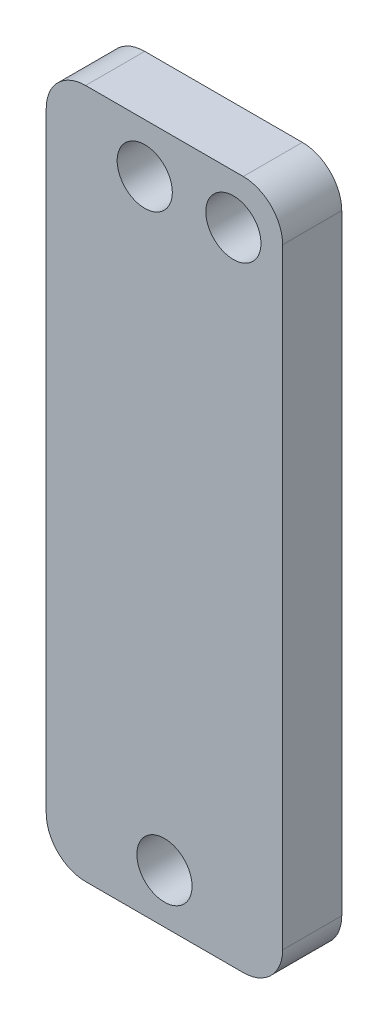
from build123d import *

# Parameters (mm, degrees)
ESQUISSE1_W             = 12
ESQUISSE1_H             = 35
ESQUISSE1_R             = 1.4
BOSS_EXTRU_1_DEPTH      = 3
ESQUISSE2_R             = 1.4
ENL_V_MAT_EXTRU_1_DEPTH = 4
CONG_1_R                = 2


with BuildPart() as part:
    # Esquisse1 → Boss.-Extru.1 (new body)
    with BuildSketch(Plane.XY):
        Rectangle(ESQUISSE1_W, ESQUISSE1_H)
        with Locations((-1, 15)):
            Circle(ESQUISSE1_R, mode=Mode.SUBTRACT)
        with Locations((0, -15)):
            Circle(ESQUISSE1_R, mode=Mode.SUBTRACT)
    extrude(amount=BOSS_EXTRU_1_DEPTH)

    # Esquisse2 → Enlèv. mat.-Extru.1 (cut, through all)
    with BuildSketch(Plane(origin=(0, 0, 0), x_dir=(-1, 0, 0), z_dir=(0, 0, -1))):
        with Locations((-3.5, 15)):
            Circle(ESQUISSE2_R)
    extrude(amount=-ENL_V_MAT_EXTRU_1_DEPTH, mode=Mode.SUBTRACT)

    # Congé1
    cong_1_edges = [part.edges().sort_by_distance(p)[0] for p in [
        (-6, 17.5, 1.5),
        (6, 17.5, 1.5),
        (6, -17.5, 1.5),
        (-6, -17.5, 1.5),
    ]]
    fillet(cong_1_edges, radius=CONG_1_R)


solid = part.part
